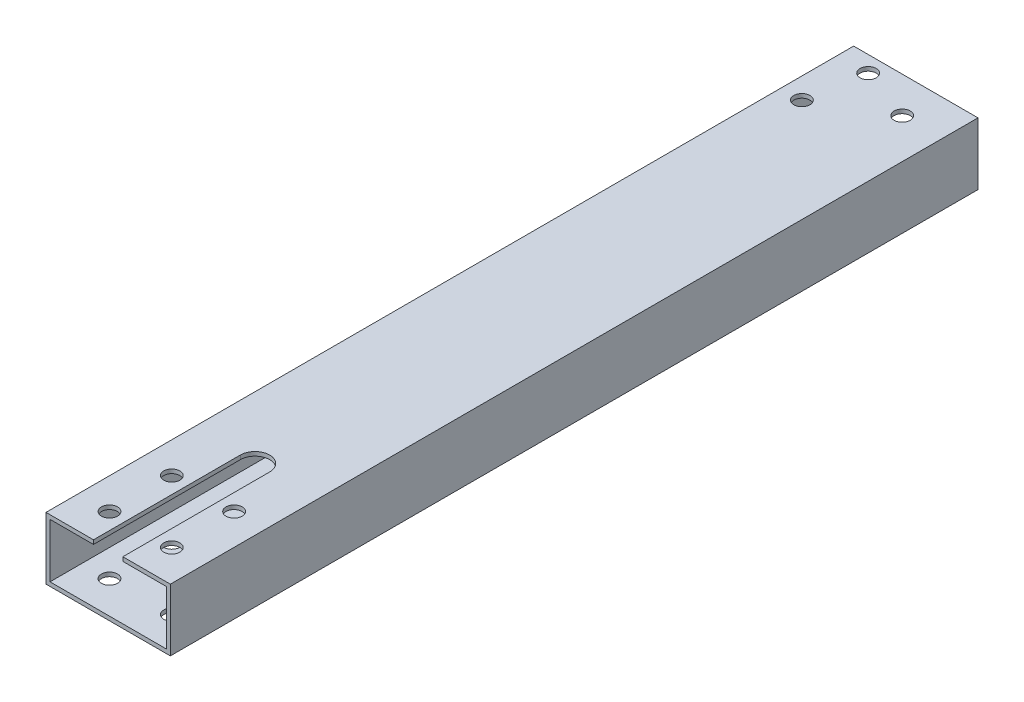
from build123d import *

# Parameters (mm, degrees)
SKETCH1_W              = 50.8
SKETCH1_H              = 25.4
SKETCH1_W_2            = 47.498
SKETCH1_H_2            = 22.098
BOSS_EXTRUDE1_DEPTH    = 330
CUT_EXTRUDE5_REACH     = 27.4
SKETCH8_R              = 3.3
CUT_EXTRUDE6_DEPTH     = 26.4
F_00_CLEARANCE_HOLE1_D = 6.600000008


with BuildPart() as part:
    # Sketch1 → Boss-Extrude1 (new body)
    with BuildSketch(Plane.XY):
        Rectangle(SKETCH1_W, SKETCH1_H)
        Rectangle(SKETCH1_W_2, SKETCH1_H_2, mode=Mode.SUBTRACT)
    extrude(amount=BOSS_EXTRUDE1_DEPTH)

    # Sketch4 → Cut-Extrude5 (cut, up to next)
    with BuildSketch(Plane(origin=(0, 12.7, 0), x_dir=(1, 0, 0), z_dir=(0, 1, 0)), mode=Mode.PRIVATE) as cut_extrude5_sk1:
        with BuildLine():
            Line((-6, -270), (-6, -330))
            Line((-6, -330), (6, -330))
            Line((6, -330), (6, -270))
            ThreePointArc((6, -270), (0, -264), (-6, -270))
        make_face()
    cut_extrude5_tool1 = extrude(cut_extrude5_sk1.sketch, amount=-CUT_EXTRUDE5_REACH, mode=Mode.PRIVATE) & part.part
    add(cut_extrude5_tool1.solids().sort_by_distance((0, 12.7, 297.629949))[0], mode=Mode.SUBTRACT)

    # Sketch8 → Cut-Extrude6 (cut, through all)
    with BuildSketch(Plane(origin=(0, 12.7, 0), x_dir=(1, 0, 0), z_dir=(0, 1, 0))):
        with BuildLine():
            ThreePointArc((-9.427922061, -316.727922061), (-9.679119604, -315.465066735), (-10.394469683, -314.394469683))
            Line((-10.394469683, -314.394469683), (-15.061374439, -319.061374439))
            ThreePointArc((-15.061374439, -319.061374439), (-11.465066735, -319.776724519), (-9.427922061, -316.727922061))
        make_face()
        with BuildLine():
            Line((-15.061374439, -319.061374439), (-10.394469683, -314.394469683))
            ThreePointArc((-10.394469683, -314.394469683), (-15.061374439, -314.394469683), (-15.061374439, -319.061374439))
        make_face()
        with Locations((-12.727922061, -291.272077939)):
            Circle(SKETCH8_R)
        with Locations((12.727922061, -291.272077939)):
            Circle(SKETCH8_R)
        with Locations((12.727922061, -316.727922061)):
            Circle(SKETCH8_R)
    extrude(amount=-CUT_EXTRUDE6_DEPTH, mode=Mode.SUBTRACT)

    # #00 Clearance Hole1 (through all)
    with Locations(Plane(origin=(136.368987279, 20.7, -48.715791339), x_dir=(0.866025404, 0, -0.5), z_dir=(0, 1, 0))):
        with Locations((-156.901570158, 26.695380774), (-141.901570158, 8.695380774), (-171.901570158, 8.695380774)):
            Hole(F_00_CLEARANCE_HOLE1_D / 2)


solid = part.part
